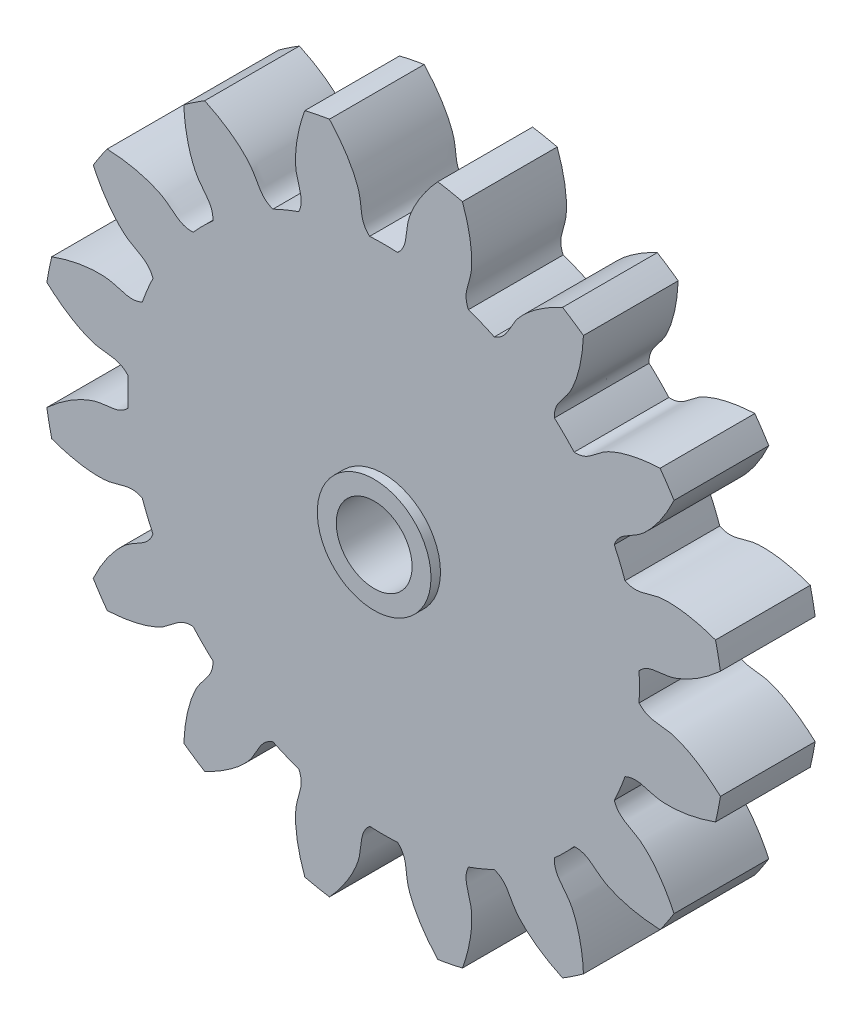
from build123d import *

# Parameters (mm, degrees)
SKETCH_1_R               = 18
EXTRUDE_1_DEPTH          = 5
CUT_EXTRUDE_1_DEPTH      = 26.942243542
PATTERN_CIRCULAR_1_COUNT = 16
SKETCH_4_R               = 3
EXTRUDE_2_DEPTH          = 0.5
SKETCH_5_R               = 2
CUT_EXTRUDE_2_DEPTH      = 26.727402013
CHAMFER_1_SIZE           = 0.5


with BuildPart() as part:
    # 草图1 → 凸台-拉伸1 (new body)
    with BuildSketch(Plane.XY):
        Circle(SKETCH_1_R)
    extrude(amount=EXTRUDE_1_DEPTH)

    # 草图2 → 切除-拉伸1 (cut, through all)
    with BuildSketch(Plane.XY):
        with BuildLine():
            ThreePointArc((0.737421808, 13.479844549), (0, 13.5), (-0.737421808, 13.479844549))
            add(Edge.make_bspline(
                [(-0.737421808, 13.479844549), (-1.265855701, 13.945634449), (-1.147846171, 14.579912974), (-1.289562412, 15.173619933), (-1.302405628, 15.223101773), (-1.317864181, 15.278107134), (-1.33615792, 15.33854981), (-1.357511549, 15.40433581), (-1.382144821, 15.475364726), (-1.410275354, 15.551529394), (-1.442117534, 15.632716096), (-1.477882616, 15.718804598), (-1.517778468, 15.809668248), (-1.562009423, 15.905174057), (-1.610776102, 16.005182794), (-1.664275246, 16.109549081), (-1.722699556, 16.218121493), (-1.786237523, 16.330742664), (-1.855073276, 16.447249391), (-1.929386416, 16.567472755), (-2.009351868, 16.691238228), (-2.095139726, 16.8183658), (-2.186915104, 16.948670102), (-2.284837993, 17.081960529), (-2.389063114, 17.21804138), (-2.499739782, 17.356711986), (-2.617011769, 17.497766853), (-2.74101717, 17.640995801), (-2.871888276, 17.786184113), (-3.009751445, 17.933112683), (-3.154726985, 18.081558164), (-3.306929031, 18.23129313), (-3.466465432, 18.382086228), (-3.633437641, 18.533702343), (-3.807940609, 18.68590276), (-3.990062679, 18.838445331), (-4.179885493, 18.991084647), (-4.377483891, 19.143572206), (-4.582925826, 19.295656588), (-4.796272275, 19.447083634), (-5.017577158, 19.597596624), (-5.246887269, 19.746936458), (-5.484242156, 19.89484184), (-5.814929608, 20.091837356), (-6.069976593, 20.233482885), (-6.243559964, 20.3254849)],
                knots=[0, 0, 0, 0, 0.190532963, 0.195486862, 0.201101281, 0.207376219, 0.214311677, 0.221907655, 0.230164153, 0.23908117, 0.248658708, 0.258896765, 0.269795342, 0.281354439, 0.293574056, 0.306454192, 0.319994848, 0.334196024, 0.34905772, 0.364579936, 0.380762672, 0.397605927, 0.415109702, 0.433273997, 0.452098812, 0.471584146, 0.491730001, 0.512536375, 0.534003269, 0.556130683, 0.578918617, 0.60236707, 0.626476044, 0.651245537, 0.67667555, 0.702766082, 0.729517135, 0.756928707, 0.7850008, 0.813733412, 0.843126544, 0.873180195, 0.903894367, 0.935269058, 1, 1, 1, 1], degree=3))
            ThreePointArc((-6.243559964, 20.3254849), (0, 21.26281678), (6.243559964, 20.3254849))
            add(Edge.make_bspline(
                [(0.737421808, 13.479844549), (1.265855701, 13.945634449), (1.147846171, 14.579912974), (1.289562412, 15.173619933), (1.302405628, 15.223101773), (1.317864181, 15.278107134), (1.33615792, 15.33854981), (1.357511549, 15.40433581), (1.382144821, 15.475364726), (1.410275354, 15.551529394), (1.442117534, 15.632716096), (1.477882616, 15.718804598), (1.517778468, 15.809668248), (1.562009423, 15.905174057), (1.610776102, 16.005182794), (1.664275246, 16.109549081), (1.722699556, 16.218121493), (1.786237523, 16.330742664), (1.855073276, 16.447249391), (1.929386416, 16.567472755), (2.009351868, 16.691238228), (2.095139726, 16.8183658), (2.186915104, 16.948670102), (2.284837993, 17.081960529), (2.389063114, 17.21804138), (2.499739782, 17.356711986), (2.617011769, 17.497766853), (2.74101717, 17.640995801), (2.871888276, 17.786184113), (3.009751445, 17.933112683), (3.154726985, 18.081558164), (3.306929031, 18.23129313), (3.466465432, 18.382086228), (3.633437641, 18.533702343), (3.807940609, 18.68590276), (3.990062679, 18.838445331), (4.179885493, 18.991084647), (4.377483891, 19.143572206), (4.582925826, 19.295656588), (4.796272275, 19.447083634), (5.017577158, 19.597596624), (5.246887269, 19.746936458), (5.484242156, 19.89484184), (5.814929608, 20.091837356), (6.069976593, 20.233482885), (6.243559964, 20.3254849)],
                knots=[0, 0, 0, 0, 0.190532963, 0.195486862, 0.201101281, 0.207376219, 0.214311677, 0.221907655, 0.230164153, 0.23908117, 0.248658708, 0.258896765, 0.269795342, 0.281354439, 0.293574056, 0.306454192, 0.319994848, 0.334196024, 0.34905772, 0.364579936, 0.380762672, 0.397605927, 0.415109702, 0.433273997, 0.452098812, 0.471584146, 0.491730001, 0.512536375, 0.534003269, 0.556130683, 0.578918617, 0.60236707, 0.626476044, 0.651245537, 0.67667555, 0.702766082, 0.729517135, 0.756928707, 0.7850008, 0.813733412, 0.843126544, 0.873180195, 0.903894367, 0.935269058, 1, 1, 1, 1], degree=3))
        make_face()
    cut_extrude_1 = extrude(amount=CUT_EXTRUDE_1_DEPTH, mode=Mode.SUBTRACT)

    # 阵列(圆周)1: 切除-拉伸1 ×16 about axis
    pattern_circular_1_axis = Axis((0, 0, -0.25), (0, 0, 1))
    for i in range(1, PATTERN_CIRCULAR_1_COUNT):
        add(cut_extrude_1.rotate(pattern_circular_1_axis, i * 360 / PATTERN_CIRCULAR_1_COUNT), mode=Mode.SUBTRACT)

    # 草图4 → 凸台-拉伸2 (add)
    with BuildSketch(Plane.XY.offset(5)):
        Circle(SKETCH_4_R)
    extrude(amount=EXTRUDE_2_DEPTH)

    # 草图5 → 切除-拉伸2 (cut, through all)
    with BuildSketch(Plane.XY.offset(5.5)):
        Circle(SKETCH_5_R)
    extrude(amount=-CUT_EXTRUDE_2_DEPTH, mode=Mode.SUBTRACT)

    # 倒角1
    chamfer_1_edges = [part.edges().sort_by_distance(p)[0] for p in [
        (-2, 0, 0),
    ]]
    chamfer(chamfer_1_edges, length=CHAMFER_1_SIZE)


solid = part.part
